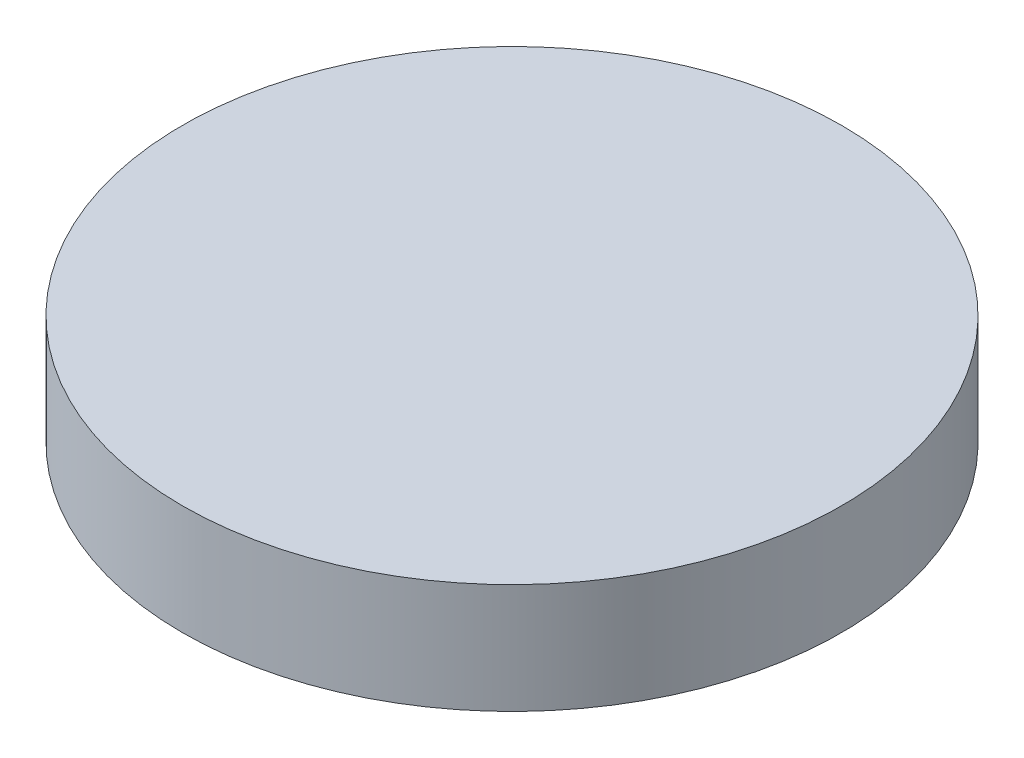
from build123d import *

# Parameters (mm, degrees)
WHEEL_R             = 30
EXTRUDE_WHEEL_DEPTH = 10


with BuildPart() as part:
    # Wheel → Extrude wheel (new body)
    with BuildSketch(Plane(origin=(0, 0, 0), x_dir=(1, 0, 0), z_dir=(0, 1, 0))):
        Circle(WHEEL_R)
    extrude(amount=EXTRUDE_WHEEL_DEPTH)


solid = part.part
